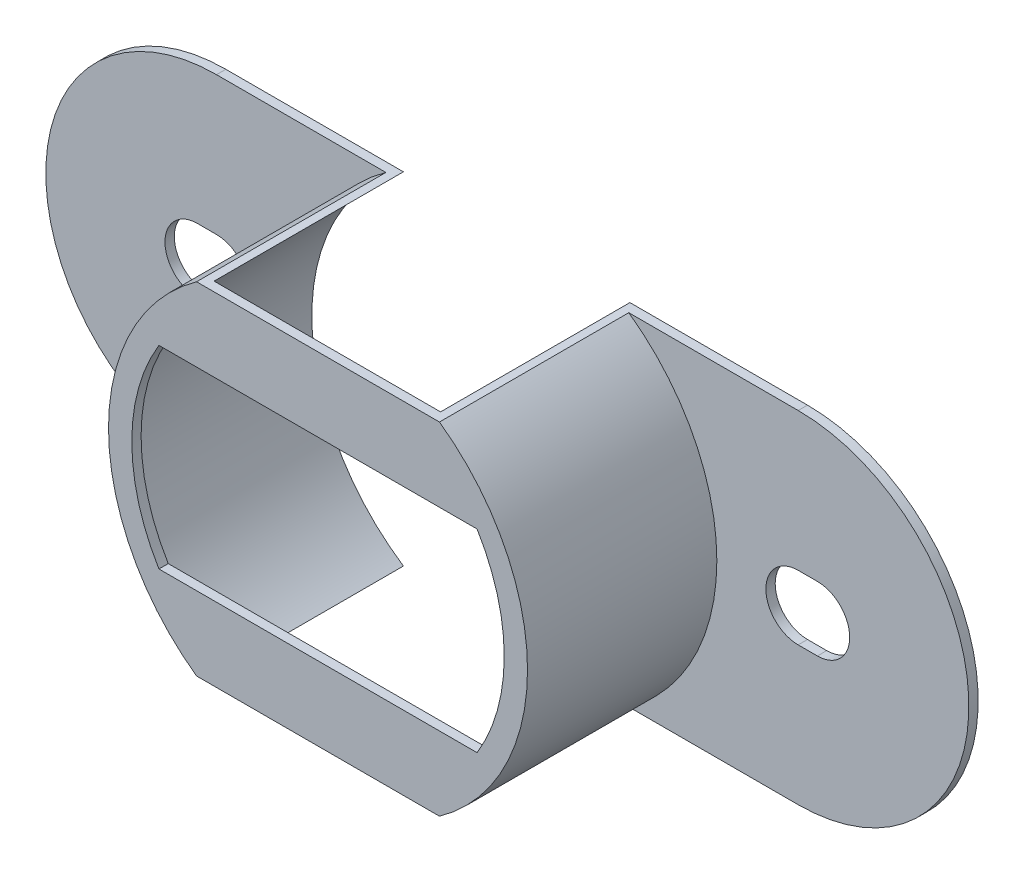
from build123d import *

# Parameters (mm, degrees)
EXTRUDE1_DEPTH     = 0.381
EXTRUDE2_DEPTH     = 7.747
CUT_EXTRUDE1_DEPTH = 7.747
CUT_EXTRUDE2_DEPTH = 9.128


with BuildPart() as part:
    # Sketch1 → Extrude1 (new body)
    with BuildSketch(Plane.XY):
        with BuildLine():
            Line((-11.8999, 6.985), (11.8999, 6.985))
            ThreePointArc((11.8999, 6.985), (18.8849, 0), (11.8999, -6.985))
            Line((11.8999, -6.985), (-11.8999, -6.985))
            ThreePointArc((-11.8999, -6.985), (-18.8849, 0), (-11.8999, 6.985))
        make_face()
        with BuildLine():
            Line((11.8999, 1.3208), (12.6873, 1.3208))
            ThreePointArc((12.6873, 1.3208), (14.0081, 0), (12.6873, -1.3208))
            Line((12.6873, -1.3208), (11.8999, -1.3208))
            ThreePointArc((11.8999, -1.3208), (10.5791, 0), (11.8999, 1.3208))
        make_face(mode=Mode.SUBTRACT)
        with BuildLine():
            Line((-12.6873, 1.3208), (-11.8999, 1.3208))
            ThreePointArc((-11.8999, 1.3208), (-10.5791, 0), (-11.8999, -1.3208))
            Line((-11.8999, -1.3208), (-12.6873, -1.3208))
            ThreePointArc((-12.6873, -1.3208), (-14.0081, 0), (-12.6873, 1.3208))
        make_face(mode=Mode.SUBTRACT)
    extrude(amount=EXTRUDE1_DEPTH)

    # Sketch2 → Extrude2 (add)
    with BuildSketch(Plane.XY.offset(0.381)):
        with BuildLine():
            Line((-4.96966108, -6.985), (4.96966108, -6.985))
            ThreePointArc((4.96966108, -6.985), (8.5725, 0), (4.96966108, 6.985))
            Line((4.96966108, 6.985), (-4.96966108, 6.985))
            ThreePointArc((-4.96966108, 6.985), (-8.5725, 0), (-4.96966108, -6.985))
        make_face()
    extrude(amount=EXTRUDE2_DEPTH)

    # Sketch3 → Cut-Extrude1 (cut)
    with BuildSketch(Plane(origin=(0, 0, 0), x_dir=(-1, 0, 0), z_dir=(0, 0, -1))):
        with BuildLine():
            Line((-4.633324832, 6.985), (4.633324832, 6.985))
            ThreePointArc((4.633324832, 6.985), (8.382, 0), (4.633324832, -6.985))
            Line((4.633324832, -6.985), (-4.633324832, -6.985))
            ThreePointArc((-4.633324832, -6.985), (-8.382, 0), (-4.633324832, 6.985))
        make_face()
    extrude(amount=-CUT_EXTRUDE1_DEPTH, mode=Mode.SUBTRACT)

    # Sketch4 → Cut-Extrude2 (cut, through all)
    with BuildSketch(Plane.XY.offset(8.128)):
        with BuildLine():
            Line((-6.508746902, 3.9624), (6.508746902, 3.9624))
            ThreePointArc((6.508746902, 3.9624), (7.62, 0), (6.508746902, -3.9624))
            Line((6.508746902, -3.9624), (-6.508746902, -3.9624))
            ThreePointArc((-6.508746902, -3.9624), (-7.62, 0), (-6.508746902, 3.9624))
        make_face()
    extrude(amount=-CUT_EXTRUDE2_DEPTH, mode=Mode.SUBTRACT)


solid = part.part
